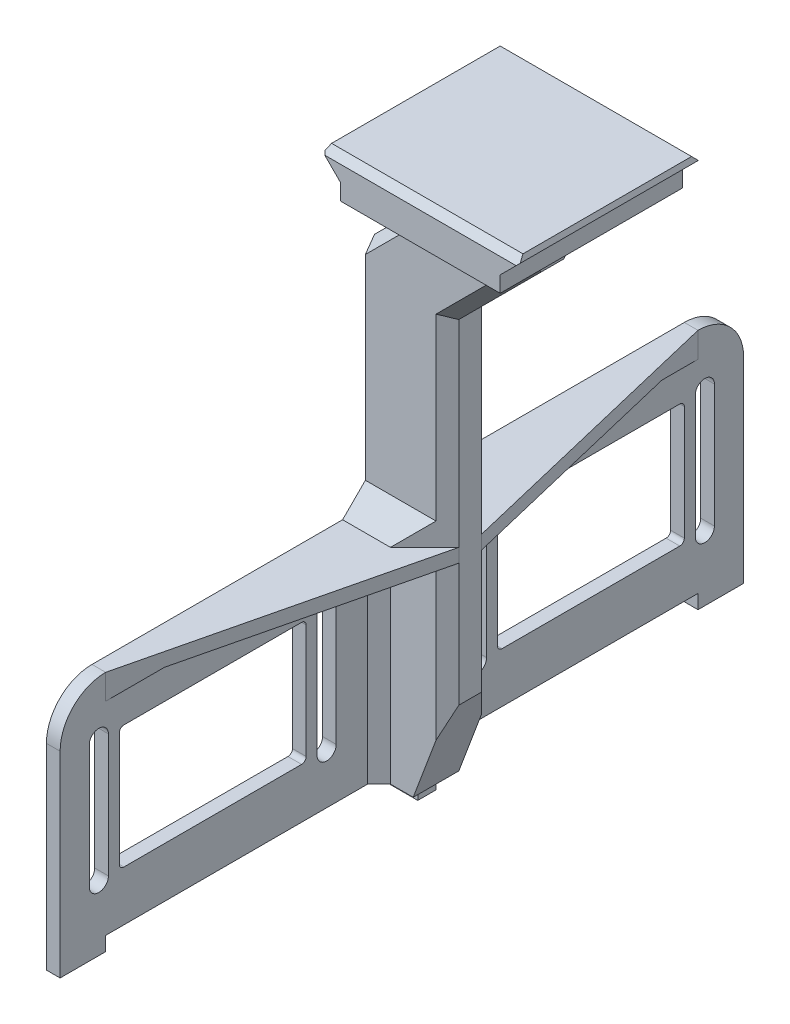
from build123d import *

# Parameters (mm, degrees)
SKETCH_2_W              = 17.5
SKETCH_2_H              = 10
EXTRUDE_1_DEPTH         = 125
SKETCH_3_W              = 50
SKETCH_3_H              = 30
EXTRUDE_2_DEPTH         = 7.5
CHAMFER_1_SIZE          = 1
EXTRUDE_3_DEPTH         = 17.5
CHAMFER_2_SIZE          = 2
CHAMFER_3_SIZE          = 2
SKETCH_6_W              = 10
SKETCH_6_H              = 3
EXTRUDE_4_DEPTH         = 3.1
SKETCH_7_W              = 70
SKETCH_7_H              = 50
EXTRUDE_5_DEPTH         = 3.25
SKETCH_15_W             = 70
SKETCH_15_H             = 50
CUT_EXTRUDE_7_DEPTH     = 0.25
SKETCH_16_W             = 41
SKETCH_16_H             = 27
CUT_EXTRUDE_8_DEPTH     = 39.25
CHAMFER_7_SIZE          = 2
FILLET_1_R              = 1
FILLET_2_R              = 10
EXTRUDE_7_DEPTH         = 3
SKETCH_19_W             = 101.779204681
SKETCH_19_H             = 48.287293129
CUT_EXTRUDE_10_DEPTH    = 7.5
SKETCH_21_W             = 30
SKETCH_21_H             = 50
EXTRUDE_8_DEPTH         = 10
EXTRUDE_9_DEPTH         = 50
SKETCH_24_W             = 6
SKETCH_24_H             = 6
EXTRUDE_10_DEPTH        = 2
CUT_EXTRUDE_11_DEPTH    = 44
CHAMFER_9_SIZE          = 3
SKETCH_27_R             = 3.5
CUT_EXTRUDE_13_DEPTH    = 31
SKETCH_28_W             = 121.830720906
SKETCH_28_H             = 94.628612201
CUT_EXTRUDE_14_DEPTH    = 75
SKETCH_29_W             = 31.647498983
SKETCH_29_H             = 23.6528393
CUT_EXTRUDE_15_DEPTH    = 75
SKETCH_30_W             = 23.6528393
SKETCH_30_H             = 50
EXTRUDE_11_DEPTH        = 3
SKETCH_31_W             = 12.609658301
SKETCH_31_H             = 23.6528393
EXTRUDE_12_DEPTH        = 3
SKETCH_33_W             = 17.8
SKETCH_33_H             = 10
EXTRUDE_13_DEPTH        = 50
SKETCH_34_W             = 10
SKETCH_34_H             = 35
CUT_EXTRUDE_16_DEPTH    = 5.75
EXTRUDE_15_DEPTH        = 10
CUT_EXTRUDE_17_DEPTH    = 37
SKETCH_38_W             = 26
SKETCH_38_H             = 99.175
EXTRUDE_16_DEPTH        = 4
CHAMFER_11_SIZE         = 1
CHAMFER_11_EDGE_2_SIZE  = 1
CHAMFER_11_EDGE_3_SIZE2 = 0.707106781
CHAMFER_11_EDGE_3_SIZE  = 1
CHAMFER_11_EDGE_4_SIZE2 = 1
CHAMFER_11_EDGE_4_SIZE  = 0.707106781
SKETCH_40_W             = 14.8
SKETCH_40_H             = 10
CUT_EXTRUDE_18_DEPTH    = 180
SKETCH_41_W             = 58.425807109
SKETCH_41_H             = 132.043018415
CUT_EXTRUDE_19_DEPTH    = 180
SKETCH_43_W             = 42.288790166
SKETCH_43_H             = 33.906174504
CUT_EXTRUDE_20_DEPTH    = 180
SKETCH_44_W             = 60.210135913
SKETCH_44_H             = 20.917157606
CUT_EXTRUDE_21_DEPTH    = 180
SKETCH_45_W             = 2
SKETCH_45_H             = 38
CUT_EXTRUDE_22_DEPTH    = 180
SKETCH_46_W             = 19.341721819
SKETCH_46_H             = 130
CUT_EXTRUDE_23_DEPTH    = 3
EXTRUDE_17_DEPTH        = 3
SKETCH_48_W             = 15
SKETCH_48_H             = 10
CUT_EXTRUDE_24_DEPTH    = 7
SKETCH_50_W             = 23.75
SKETCH_50_H             = 10
EXTRUDE_18_DEPTH        = 90
EXTRUDE_19_DEPTH        = 10
SKETCH_53_W             = 5.75
SKETCH_53_H             = 10
EXTRUDE_20_DEPTH        = 106
SKETCH_55_W             = 5.75
SKETCH_55_H             = 10
CUT_EXTRUDE_25_DEPTH    = 106
EXTRUDE_21_DEPTH        = 20
CUT_EXTRUDE_26_DEPTH    = 20
EXTRUDE_22_DEPTH        = 10
CHAMFER_14_SIZE         = 2.5
CHAMFER_15_SIZE         = 2.5
CHAMFER_16_SIZE         = 1.5
CHAMFER_17_SIZE         = 1.5
CUT_EXTRUDE_27_DEPTH    = 10
CHAMFER_18_SIZE         = 5
SKETCH_62_W             = 2.25
SKETCH_62_H             = 3
EXTRUDE_24_DEPTH        = 3.1
SKETCH_63_W             = 1.75
SKETCH_63_H             = 3
CUT_EXTRUDE_28_DEPTH    = 3.1
SKETCH_64_W             = 10.5
SKETCH_64_H             = 3
CUT_EXTRUDE_29_DEPTH    = 3.1
CHAMFER_19_SIZE         = 2
SKETCH_65_W             = 3
SKETCH_65_H             = 3.1
EXTRUDE_25_DEPTH        = 10
SKETCH_66_W             = 3
SKETCH_66_H             = 3.1
EXTRUDE_26_DEPTH        = 10
SKETCH_67_W             = 8.5
SKETCH_67_H             = 4
EXTRUDE_27_DEPTH        = 3.1


with BuildPart() as part:
    # Sketch 2 → Extrude 1 (new body)
    with BuildSketch(Plane(origin=(0, 0, 0), x_dir=(1, 0, 0), z_dir=(0, 1, 0))):
        with Locations((8.75, 5)):
            Rectangle(SKETCH_2_W, SKETCH_2_H)
    extrude(amount=EXTRUDE_1_DEPTH)

    # Sketch 3 → Extrude 2 (add)
    with BuildSketch(Plane(origin=(0, 125, 0), x_dir=(1, 0, 0), z_dir=(0, 1, 0))):
        with Locations((8.75, 5)):
            Rectangle(SKETCH_3_W, SKETCH_3_H)
    extrude(amount=EXTRUDE_2_DEPTH)

    # Chamfer 1
    chamfer_1_edges = [part.edges().sort_by_distance(p)[0] for p in [
        (33.75, 132.5, -5),
        (8.75, 132.5, -20),
        (-16.25, 132.5, -5),
        (8.75, 132.5, 10),
    ]]
    chamfer(chamfer_1_edges, length=CHAMFER_1_SIZE)

    # Sketch 5 → Extrude 3 (add)
    with BuildSketch(Plane(origin=(17.5, 0, 0), x_dir=(0, 0, -1), z_dir=(1, 0, 0))):
        Polygon((10, 125), (20, 125), (10, 110), align=None)
        Polygon((0, 125), (-10, 125), (0, 110), align=None)
    extrude(amount=-EXTRUDE_3_DEPTH)

    # Chamfer 2
    chamfer_2_edges = [part.edges().sort_by_distance(p)[0] for p in [
        (-8.125, 125, -20),
        (33.75, 125, -5),
        (-16.25, 125, -5),
        (-8.125, 125, 10),
        (25.625, 125, -20),
        (25.625, 125, 10),
    ]]
    chamfer(chamfer_2_edges, length=CHAMFER_2_SIZE)

    # Chamfer 3
    chamfer_3_edges = [part.edges().sort_by_distance(p)[0] for p in [
        (0, 55, -10),
        (17.5, 55, -10),
        (17.5, 55, 0),
        (0, 55, 0),
    ]]
    chamfer(chamfer_3_edges, length=CHAMFER_3_SIZE)

    # Sketch 6 → Extrude 4 (add)
    with BuildSketch(Plane.XZ):
        with Locations((8.75, -5)):
            Rectangle(SKETCH_6_W, SKETCH_6_H)
    extrude(amount=EXTRUDE_4_DEPTH)

    # Sketch 7 → Extrude 5 (add)
    with BuildSketch(Plane.ZY.offset(-8.75)):
        with Locations((-45, 25)):
            Rectangle(SKETCH_7_W, SKETCH_7_H)
    extrude_5 = extrude(amount=EXTRUDE_5_DEPTH)

    # Mirror 1: Extrude 5 across plane
    add(extrude_5.mirror(Plane(origin=(0, 0, -5), x_dir=(1, 0, 0), z_dir=(0, 0, -1))))

    # Sketch 15 → Cut-Extrude 7 (cut)
    with BuildSketch(Plane(origin=(8.75, 0, 0), x_dir=(0, 0, -1), z_dir=(1, 0, 0))):
        with Locations((-35, 25)):
            Rectangle(SKETCH_15_W, SKETCH_15_H)
        with Locations((45, 25)):
            Rectangle(SKETCH_15_W, SKETCH_15_H)
    extrude(amount=-CUT_EXTRUDE_7_DEPTH, mode=Mode.SUBTRACT)

    # Sketch 16 → Cut-Extrude 8 (cut)
    with BuildSketch(Plane.ZY.offset(-5.5)):
        with Locations((-46.5, 24.5)):
            Rectangle(SKETCH_16_W, SKETCH_16_H)
        with Locations((36.5, 24.5)):
            Rectangle(SKETCH_16_W, SKETCH_16_H)
    extrude(amount=-CUT_EXTRUDE_8_DEPTH, mode=Mode.SUBTRACT)

    # Chamfer 7
    chamfer_7_edges = [part.edges().sort_by_distance(p)[0] for p in [
        (5.5, 25, -10),
        (5.5, 25, 0),
        (8.5, 25, 0),
        (8.5, 25, -10),
    ]]
    chamfer(chamfer_7_edges, length=CHAMFER_7_SIZE)

    # Fillet 1
    fillet_1_edges = [part.edges().sort_by_distance(p)[0] for p in [
        (7, 38, -26),
        (7, 11, -26),
        (7, 11, -67),
        (7, 38, -67),
        (7, 11, 16),
        (7, 38, 16),
        (7, 38, 57),
        (7, 11, 57),
    ]]
    fillet(fillet_1_edges, radius=FILLET_1_R)

    # Fillet 2
    fillet_2_edges = [part.edges().sort_by_distance(p)[0] for p in [
        (7, 50, -80),
        (7, 50, 70),
    ]]
    fillet(fillet_2_edges, radius=FILLET_2_R)

    # Sketch 17 → Extrude 7 (add)
    with BuildSketch(Plane(origin=(0, 50, 0), x_dir=(1, 0, 0), z_dir=(0, 1, 0))):
        Polygon((5.5, 70), (-9.5, 20), (-9.5, -10), (5.5, -60), align=None)
    extrude(amount=-EXTRUDE_7_DEPTH)

    # Sketch 19 → Cut-Extrude 10 (cut)
    with BuildSketch(Plane(origin=(0, 132.5, 0), x_dir=(1, 0, 0), z_dir=(0, 1, 0))):
        with Locations((10.051154605, 7.674595578)):
            Rectangle(SKETCH_19_W, SKETCH_19_H)
    extrude(amount=-CUT_EXTRUDE_10_DEPTH, mode=Mode.SUBTRACT)

    # Sketch 21 → Extrude 8 (add)
    with BuildSketch(Plane(origin=(0, 125, 0), x_dir=(1, 0, 0), z_dir=(0, 1, 0))):
        with Locations((8.75, 5)):
            Rectangle(SKETCH_21_W, SKETCH_21_H)
    extrude(amount=EXTRUDE_8_DEPTH)

    # Sketch 23 → Extrude 9 (add)
    with BuildSketch(Plane.XY.offset(20)):
        Polygon((23.75, 130), (23.75, 135), (28.75, 135), align=None)
        Polygon((-11.25, 135), (-6.25, 135), (-6.25, 130), align=None)
    extrude(amount=-EXTRUDE_9_DEPTH)

    # Sketch 24 → Extrude 10 (add)
    with BuildSketch(Plane.ZY):
        with Locations((-5, 3)):
            Rectangle(SKETCH_24_W, SKETCH_24_H)
    extrude(amount=EXTRUDE_10_DEPTH)

    # Sketch 25 → Cut-Extrude 11 (cut)
    with BuildSketch(Plane(origin=(8.5, 0, 0), x_dir=(0, 0, -1), z_dir=(1, 0, 0))):
        with BuildLine():
            Line((-13.6, 11), (-13.6, 38))
            ThreePointArc((-13.6, 38), (-11.5, 40.1), (-9.4, 38))
            Line((-9.4, 38), (-9.4, 11))
            ThreePointArc((-9.4, 11), (-11.5, 8.9), (-13.6, 11))
        make_face()
        with BuildLine():
            Line((-59.4, 11), (-59.4, 38))
            ThreePointArc((-59.4, 38), (-61.5, 40.1), (-63.6, 38))
            Line((-63.6, 38), (-63.6, 11))
            ThreePointArc((-63.6, 11), (-61.5, 8.9), (-59.4, 11))
        make_face()
        with BuildLine():
            Line((23.6, 11), (23.6, 38))
            ThreePointArc((23.6, 38), (21.5, 40.1), (19.4, 38))
            Line((19.4, 38), (19.4, 11))
            ThreePointArc((19.4, 11), (21.5, 8.9), (23.6, 11))
        make_face()
        with BuildLine():
            Line((69.4, 11), (69.4, 38))
            ThreePointArc((69.4, 38), (71.5, 40.1), (73.6, 38))
            Line((73.6, 38), (73.6, 11))
            ThreePointArc((73.6, 11), (71.5, 8.9), (69.4, 11))
        make_face()
    extrude(amount=-CUT_EXTRUDE_11_DEPTH, mode=Mode.SUBTRACT)

    # Chamfer 9
    chamfer_9_edges = [part.edges().sort_by_distance(p)[0] for p in [
        (17.5, 125, -5),
        (0, 125, -5),
    ]]
    chamfer(chamfer_9_edges, length=CHAMFER_9_SIZE)

    # Sketch 27 → Cut-Extrude 13 (cut)
    with BuildSketch(Plane.ZY):
        with Locations((-5, 115.5)):
            Circle(SKETCH_27_R)
    extrude(amount=-CUT_EXTRUDE_13_DEPTH, mode=Mode.SUBTRACT)

    # Sketch 28 → Cut-Extrude 14 (cut)
    with BuildSketch(Plane(origin=(0, 50, 0), x_dir=(1, 0, 0), z_dir=(0, 1, 0))):
        with Locations((13.662817894, 0.297507804)):
            Rectangle(SKETCH_28_W, SKETCH_28_H)
    extrude(amount=CUT_EXTRUDE_14_DEPTH, mode=Mode.SUBTRACT)

    # Sketch 29 → Cut-Extrude 15 (cut)
    with BuildSketch(Plane.XZ):
        with Locations((8.714091191, -5.118405237)):
            Rectangle(SKETCH_29_W, SKETCH_29_H)
    extrude(amount=-CUT_EXTRUDE_15_DEPTH, mode=Mode.SUBTRACT)

    # Sketch 30 → Extrude 11 (add)
    with BuildSketch(Plane(origin=(8.5, 0, 0), x_dir=(0, 0, -1), z_dir=(1, 0, 0))):
        with Locations((5.118405237, 25)):
            Rectangle(SKETCH_30_W, SKETCH_30_H)
    extrude(amount=-EXTRUDE_11_DEPTH)

    # Sketch 31 → Extrude 12 (add)
    with BuildSketch(Plane(origin=(0, 50, 0), x_dir=(1, 0, 0), z_dir=(0, 1, 0))):
        with Locations((-0.804829151, 5.118405237)):
            Rectangle(SKETCH_31_W, SKETCH_31_H)
    extrude(amount=-EXTRUDE_12_DEPTH)

    # Sketch 33 → Extrude 13 (add)
    with BuildSketch(Plane(origin=(0, 0, 0), x_dir=(1, 0, 0), z_dir=(0, 1, 0))):
        with Locations((8.65, 5)):
            Rectangle(SKETCH_33_W, SKETCH_33_H)
    extrude(amount=EXTRUDE_13_DEPTH)

    # Sketch 34 → Cut-Extrude 16 (cut)
    with BuildSketch(Plane.ZY.offset(0.25)):
        with Locations((-5, 29.5)):
            Rectangle(SKETCH_34_W, SKETCH_34_H)
    extrude(amount=-CUT_EXTRUDE_16_DEPTH, mode=Mode.SUBTRACT)

    # Sketch 36 → Extrude 15 (add)
    with BuildSketch(Plane.XY):
        Polygon((17.55, 0), (32.55, 0), (32.55, 125), (17.55, 125), (-6.25, 125), (17.55, 101.2), align=None)
    extrude(amount=-EXTRUDE_15_DEPTH)

    # Sketch 37 → Cut-Extrude 17 (cut)
    with BuildSketch(Plane.XY.offset(8)):
        Polygon((20.525, 0), (32.55, 0), (32.55, 12.025), align=None)
        Polygon((23.75, 125), (32.55, 116.2), (32.55, 125), align=None)
    extrude(amount=-CUT_EXTRUDE_17_DEPTH, mode=Mode.SUBTRACT)

    # Sketch 38 → Extrude 16 (add)
    with BuildSketch(Plane(origin=(28.55, 0, 0), x_dir=(0, 0, -1), z_dir=(1, 0, 0))):
        with Locations((5, 66.6125)):
            Rectangle(SKETCH_38_W, SKETCH_38_H)
    extrude(amount=EXTRUDE_16_DEPTH)

    # Chamfer 11
    chamfer_11_edges = [part.edges().sort_by_distance(p)[0] for p in [
        (8.75, 135, -30),
    ]]
    chamfer(chamfer_11_edges, length=CHAMFER_11_SIZE)

    # Chamfer 11 edge 2
    chamfer_11_edge_2_edges = [part.edges().sort_by_distance(p)[0] for p in [
        (8.75, 135, 20),
    ]]
    chamfer(chamfer_11_edge_2_edges, length=CHAMFER_11_EDGE_2_SIZE)

    # Chamfer 11 edge 3
    chamfer_11_edge_3_edges = [part.edges().sort_by_distance(p)[0] for p in [
        (28.75, 135, -5),
    ]]
    chamfer(chamfer_11_edge_3_edges, length=CHAMFER_11_EDGE_3_SIZE, length2=CHAMFER_11_EDGE_3_SIZE2)

    # Chamfer 11 edge 4
    chamfer_11_edge_4_edges = [part.edges().sort_by_distance(p)[0] for p in [
        (-11.25, 135, -5),
    ]]
    chamfer(chamfer_11_edge_4_edges, length=CHAMFER_11_EDGE_4_SIZE, length2=CHAMFER_11_EDGE_4_SIZE2)

    # Sketch 40 → Cut-Extrude 18 (cut)
    with BuildSketch(Plane.XZ):
        with Locations((25.15, -5)):
            Rectangle(SKETCH_40_W, SKETCH_40_H)
    extrude(amount=-CUT_EXTRUDE_18_DEPTH, mode=Mode.SUBTRACT)

    # Sketch 41 → Cut-Extrude 19 (cut)
    with BuildSketch(Plane.XY):
        with Locations((39.712903555, 78.021509208)):
            Rectangle(SKETCH_41_W, SKETCH_41_H)
    extrude(amount=-CUT_EXTRUDE_19_DEPTH, mode=Mode.SUBTRACT)

    # Sketch 43 → Cut-Extrude 20 (cut)
    with BuildSketch(Plane.XY.offset(8)):
        Polygon((28.55, 105.154838034), (28.55, 17.025), (32.55, 17.025), (32.55, 116.2), (28.55, 116.2), align=None)
        with Locations((7.405604917, 122.107925286)):
            Rectangle(SKETCH_43_W, SKETCH_43_H)
    extrude(amount=-CUT_EXTRUDE_20_DEPTH, mode=Mode.SUBTRACT)

    # Sketch 44 → Cut-Extrude 21 (cut)
    with BuildSketch(Plane(origin=(0, 0, 8), x_dir=(-1, 0, 0), z_dir=(0, 0, -1))):
        with Locations((-6.110520367, 129.607046371)):
            Rectangle(SKETCH_44_W, SKETCH_44_H)
    extrude(amount=-CUT_EXTRUDE_21_DEPTH, mode=Mode.SUBTRACT)

    # Sketch 45 → Cut-Extrude 22 (cut)
    with BuildSketch(Plane(origin=(0, 0, -10), x_dir=(-1, 0, 0), z_dir=(0, 0, -1))):
        with Locations((-9.5, 31)):
            Rectangle(SKETCH_45_W, SKETCH_45_H)
    extrude(amount=-CUT_EXTRUDE_22_DEPTH, mode=Mode.SUBTRACT)

    # Sketch 46 → Cut-Extrude 23 (cut)
    with BuildSketch(Plane(origin=(0, 50, 0), x_dir=(1, 0, 0), z_dir=(0, 1, 0))):
        with Locations((-4.170860909, 5)):
            Rectangle(SKETCH_46_W, SKETCH_46_H)
    extrude(amount=-CUT_EXTRUDE_23_DEPTH, mode=Mode.SUBTRACT)

    # Sketch 47 → Extrude 17 (add)
    with BuildSketch(Plane(origin=(0, 50, 0), x_dir=(1, 0, 0), z_dir=(0, 1, 0))):
        Polygon((8.5, 70), (23.5, 10), (23.5, 0), (8.5, -60), align=None)
    extrude(amount=-EXTRUDE_17_DEPTH)

    # Sketch 48 → Cut-Extrude 24 (cut)
    with BuildSketch(Plane(origin=(0, 12, 0), x_dir=(1, 0, 0), z_dir=(0, 1, 0))):
        with Locations((16, 5)):
            Rectangle(SKETCH_48_W, SKETCH_48_H)
    extrude(amount=-CUT_EXTRUDE_24_DEPTH, mode=Mode.SUBTRACT)

    # Sketch 50 → Extrude 18 (add)
    with BuildSketch(Plane(origin=(0, 5, 0), x_dir=(1, 0, 0), z_dir=(0, 1, 0))):
        with Locations((11.625, 5)):
            Rectangle(SKETCH_50_W, SKETCH_50_H)
    extrude(amount=EXTRUDE_18_DEPTH)

    # Sketch 52 → Extrude 19 (add)
    with BuildSketch(Plane(origin=(0, 0, -10), x_dir=(-1, 0, 0), z_dir=(0, 0, -1))):
        Polygon((0.25, 95), (-23.58290229, 118.83290229), (-41.58290229, 118.83290229), (-41.58290229, 111.377058167), (-23.5, 93.294155877), (-23.5, 95), align=None)
    extrude(amount=-EXTRUDE_19_DEPTH)

    # Sketch 53 → Extrude 20 (add)
    with BuildSketch(Plane.XZ):
        with Locations((20.625, -5)):
            Rectangle(SKETCH_53_W, SKETCH_53_H)
    extrude(amount=-EXTRUDE_20_DEPTH)

    # Sketch 55 → Cut-Extrude 25 (cut)
    with BuildSketch(Plane.XZ):
        with Locations((2.625, -5)):
            Rectangle(SKETCH_55_W, SKETCH_55_H)
    extrude(amount=-CUT_EXTRUDE_25_DEPTH, mode=Mode.SUBTRACT)

    # Sketch 56 → Extrude 21 (add)
    with BuildSketch(Plane.XY.offset(-5)):
        Polygon((15.08290229, 118.83290229), (50.08290229, 118.83290229), (50.08290229, 123.83290229), (55.08290229, 128.83290229), (47.58290229, 128.83290229), (15.08290229, 128.83290229), (10.08290229, 128.83290229), (15.08290229, 123.83290229), align=None)
    extrude_21 = extrude(amount=EXTRUDE_21_DEPTH)

    # Mirror 2: Extrude 21 across plane
    add(extrude_21.mirror(Plane.XY.offset(-5)))

    # Sketch 59 → Cut-Extrude 26 (cut)
    with BuildSketch(Plane.XY):
        Polygon((16, 0), (23.5, 20), (23.5, 0), align=None)
    extrude(amount=-CUT_EXTRUDE_26_DEPTH, mode=Mode.SUBTRACT)

    # Sketch 60 → Extrude 22 (add)
    with BuildSketch(Plane.XY):
        Polygon((15.08290229, 118.83290229), (15.08290229, 110.33290229), (23.58290229, 118.83290229), align=None)
    extrude(amount=-EXTRUDE_22_DEPTH)

    # Chamfer 14
    chamfer_14_edges = [part.edges().sort_by_distance(p)[0] for p in [
        (8.5, 47, -40),
        (8.5, 23.5, -10),
        (8.5, 47, 30),
        (23.5, 33.5, 0),
        (23.5, 33.5, -10),
        (23.5, 71.647077939, -10),
        (23.5, 71.647077939, 0),
        (32.541451145, 102.335607022, 0),
        (32.541451145, 102.335607022, -10),
        (8.5, 23.5, 0),
    ]]
    chamfer(chamfer_14_edges, length=CHAMFER_14_SIZE)

    # Chamfer 15
    chamfer_15_edges = [part.edges().sort_by_distance(p)[0] for p in [
        (28.33290229, 118.83290229, 0),
        (41.58290229, 118.83290229, -5),
        (28.33290229, 118.83290229, -10),
    ]]
    chamfer(chamfer_15_edges, length=CHAMFER_15_SIZE)

    # Chamfer 16
    chamfer_16_edges = [part.edges().sort_by_distance(p)[0] for p in [
        (10.08290229, 128.83290229, -5),
        (32.58290229, 128.83290229, 15),
        (55.08290229, 128.83290229, -5),
        (32.58290229, 128.83290229, -25),
    ]]
    chamfer(chamfer_16_edges, length=CHAMFER_16_SIZE)

    # Chamfer 17
    chamfer_17_edges = [part.edges().sort_by_distance(p)[0] for p in [
        (15.08290229, 118.83290229, 8.75),
        (50.08290229, 118.83290229, -5),
        (32.58290229, 118.83290229, 15),
        (32.58290229, 118.83290229, -25),
        (15.08290229, 118.83290229, -18.75),
    ]]
    chamfer(chamfer_17_edges, length=CHAMFER_17_SIZE)

    # Sketch 61 → Cut-Extrude 27 (cut)
    with BuildSketch(Plane(origin=(0, 50, 0), x_dir=(1, 0, 0), z_dir=(0, 1, 0))):
        Polygon((8.5, -60), (23.5, 2.5), (23.5, 0), align=None)
        Polygon((23.5, 10), (8.5, 70), (23.5, 7.5), align=None)
    extrude(amount=-CUT_EXTRUDE_27_DEPTH, mode=Mode.SUBTRACT)

    # Chamfer 18
    chamfer_18_edges = [part.edges().sort_by_distance(p)[0] for p in [
        (13.25, 50, -10),
        (13.25, 50, 0),
    ]]
    chamfer(chamfer_18_edges, length=CHAMFER_18_SIZE)

    # Sketch 62 → Extrude 24 (add)
    with BuildSketch(Plane.XZ):
        with Locations((14.875, -5)):
            Rectangle(SKETCH_62_W, SKETCH_62_H)
    extrude(amount=EXTRUDE_24_DEPTH)

    # Sketch 63 → Cut-Extrude 28 (cut)
    with BuildSketch(Plane.XZ.offset(3.1)):
        with Locations((4.625, -5)):
            Rectangle(SKETCH_63_W, SKETCH_63_H)
    extrude(amount=-CUT_EXTRUDE_28_DEPTH, mode=Mode.SUBTRACT)

    # Sketch 64 → Cut-Extrude 29 (cut)
    with BuildSketch(Plane.XZ.offset(3.1)):
        with Locations((10.75, -5)):
            Rectangle(SKETCH_64_W, SKETCH_64_H)
    extrude(amount=-CUT_EXTRUDE_29_DEPTH, mode=Mode.SUBTRACT)

    # Chamfer 19
    chamfer_19_edges = [part.edges().sort_by_distance(p)[0] for p in [
        (10.291451145, 105.541451145, -10),
        (10.291451145, 105.541451145, 0),
        (15.08290229, 113.33290229, -10),
        (15.08290229, 113.33290229, 0),
    ]]
    chamfer(chamfer_19_edges, length=CHAMFER_19_SIZE)

    # Sketch 65 → Extrude 25 (add)
    with BuildSketch(Plane.XY.offset(70)):
        with Locations((7, -1.55)):
            Rectangle(SKETCH_65_W, SKETCH_65_H)
    extrude(amount=-EXTRUDE_25_DEPTH)

    # Sketch 66 → Extrude 26 (add)
    with BuildSketch(Plane(origin=(0, 0, -80), x_dir=(-1, 0, 0), z_dir=(0, 0, -1))):
        with Locations((-7, -1.55)):
            Rectangle(SKETCH_66_W, SKETCH_66_H)
    extrude(amount=-EXTRUDE_26_DEPTH)

    # Sketch 67 → Extrude 27 (add)
    with BuildSketch(Plane.XZ):
        with Locations((9.75, -5)):
            Rectangle(SKETCH_67_W, SKETCH_67_H)
    extrude(amount=EXTRUDE_27_DEPTH)


solid = part.part
